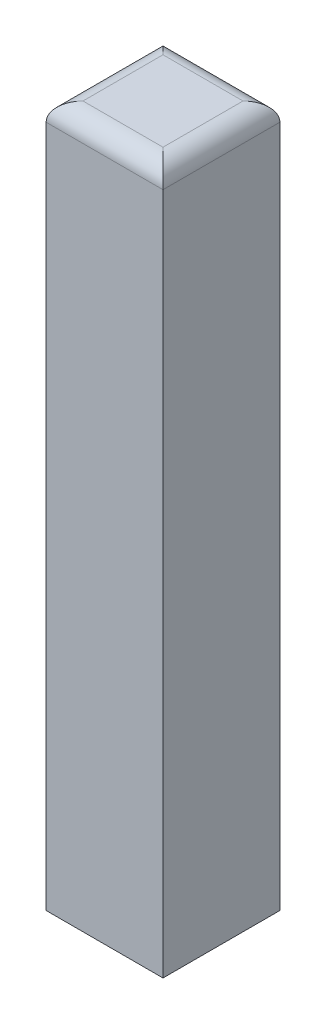
from build123d import *

# Parameters (mm, degrees)
SKETCH1_W           = 127
SKETCH1_H           = 762
BOSS_EXTRUDE1_DEPTH = 127
FILLET3_R           = 20


with BuildPart() as part:
    # Sketch1 → Boss-Extrude1 (new body)
    with BuildSketch(Plane.XY):
        with Locations((63.5, 381)):
            Rectangle(SKETCH1_W, SKETCH1_H)
    extrude(amount=BOSS_EXTRUDE1_DEPTH)

    # Fillet3
    fillet3_edges = [part.edges().sort_by_distance(p)[0] for p in [
        (63.5, 762, 127),
        (63.5, 762, 0),
        (0, 762, 63.5),
        (127, 762, 63.5),
    ]]
    fillet(fillet3_edges, radius=FILLET3_R)


solid = part.part
